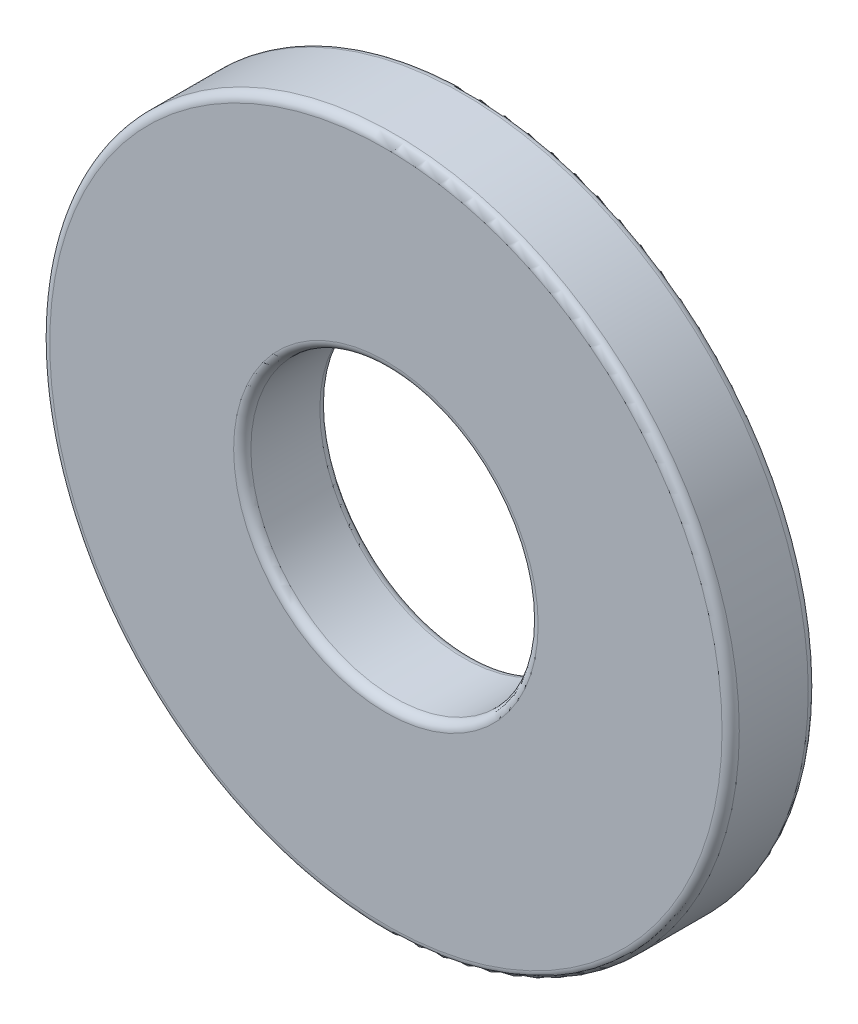
from build123d import *

# Parameters (mm, degrees)
SKETCH1_R           = 6
SKETCH1_R_2         = 2.5
BOSS_EXTRUDE1_DEPTH = 1.5
FILLET1_R           = 0.15


with BuildPart() as part:
    # Sketch1 → Boss-Extrude1 (new body)
    with BuildSketch(Plane.XY):
        Circle(SKETCH1_R)
        Circle(SKETCH1_R_2, mode=Mode.SUBTRACT)
    extrude(amount=BOSS_EXTRUDE1_DEPTH)

    # Fillet1
    fillet1_edges = [part.edges().sort_by_distance(p)[0] for p in [
        (-6, 0, 0),
        (-6, 0, 1.5),
        (-2.5, 0, 0),
        (-2.5, 0, 1.5),
    ]]
    fillet(fillet1_edges, radius=FILLET1_R)


solid = part.part
